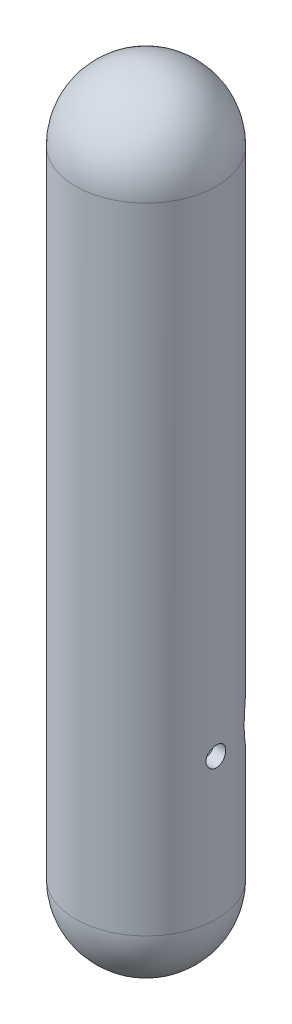
from build123d import *

# Parameters (mm, degrees)
SKETCH_1_W                      = 10
SKETCH_1_H                      = 110
CUT_EXTRUDE_1_REACH             = 112.905
SKETCH_2_R                      = 8.2
CUT_EXTRUDE_1_DIRECTION_2_DEPTH = 5
CUT_EXTRUDE_2_DEPTH             = 111.905365182
CUT_EXTRUDE_2_DEPTH_BACK        = 111.905365182
SKETCH_3_R                      = 1.4
FILLET_1_R                      = 10
FILLET_2_R                      = 10


with BuildPart() as part:
    # 草图1 → 旋转1 (revolve)
    with BuildSketch(Plane.XY):
        with Locations((5, 55)):
            Rectangle(SKETCH_1_W, SKETCH_1_H)
    revolve(axis=Axis((0, 0, 0), (0, 1, 0)))

    # 草图2 → 切除-拉伸1 (cut, up to next)
    with BuildSketch(Plane.XY, mode=Mode.PRIVATE) as cut_extrude_1_sk1:
        with Locations((0, 30)):
            Circle(SKETCH_2_R)
    cut_extrude_1_tool1 = extrude(cut_extrude_1_sk1.sketch, amount=-CUT_EXTRUDE_1_REACH, mode=Mode.PRIVATE) & part.part
    add(cut_extrude_1_tool1.solids().sort_by_distance((0, 30, 0))[0], mode=Mode.SUBTRACT)

    # 草图2 → 切除-拉伸1 direction 2 (cut)
    with BuildSketch(Plane.XY):
        with Locations((0, 30)):
            Circle(SKETCH_2_R)
    extrude(amount=CUT_EXTRUDE_1_DIRECTION_2_DEPTH, mode=Mode.SUBTRACT)

    # 草图3 → 切除-拉伸2 (cut, two sides: drawn at the far end of the back side and taken through both)
    with BuildSketch(Plane(origin=(0, 0, 0), x_dir=(0, 0, -1), z_dir=(1, 0, 0)).offset(-CUT_EXTRUDE_2_DEPTH_BACK)):
        with Locations((0, 30)):
            Circle(SKETCH_3_R)
    extrude(amount=CUT_EXTRUDE_2_DEPTH + CUT_EXTRUDE_2_DEPTH_BACK, mode=Mode.SUBTRACT)

    # 圆角1
    fillet_1_edges = [part.edges().sort_by_distance(p)[0] for p in [
        (-10, 0, 0),
    ]]
    fillet(fillet_1_edges, radius=FILLET_1_R)

    # 圆角2
    fillet_2_edges = [part.edges().sort_by_distance(p)[0] for p in [
        (-10, 110, 0),
    ]]
    fillet(fillet_2_edges, radius=FILLET_2_R)


solid = part.part
